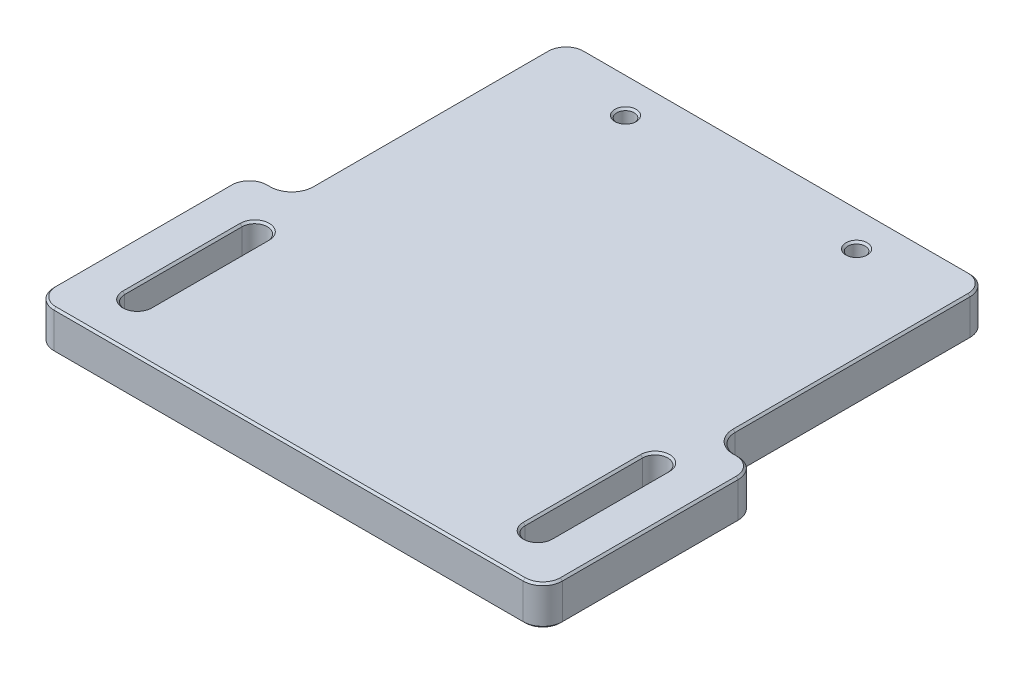
from build123d import *

# Parameters (mm, degrees)
SKETCH1_W                 = 66
SKETCH1_H                 = 63.5
BOSS_EXTRUDE1_DEPTH       = 5.08
SKETCH6_W                 = 5.5
SKETCH6_H                 = 35.589114281
CUT_EXTRUDE1_DEPTH        = 5.08
F_4_40_TAPPED_HOLE1_D     = 2.2606
F_4_40_TAPPED_HOLE1_DEPTH = 7.5946
F_4_40_TAPPED_HOLE1_TIP   = 0.679152758
FILLET1_R                 = 2.54
FILLET2_R                 = 2.54
CUT_EXTRUDE2_DEPTH        = 6.08
CHAMFER1_SIZE             = 0.254


with BuildPart() as part:
    # Sketch1 → Boss-Extrude1 (new body)
    with BuildSketch(Plane(origin=(0, 0, 0), x_dir=(1, 0, 0), z_dir=(0, 1, 0))):
        with Locations((-33, 31.75)):
            Rectangle(SKETCH1_W, SKETCH1_H)
    extrude(amount=BOSS_EXTRUDE1_DEPTH)

    # Sketch6 → Cut-Extrude1 (cut)
    with BuildSketch(Plane(origin=(0, 5.08, 0), x_dir=(1, 0, 0), z_dir=(0, 1, 0))):
        with Locations((-63.25, 45.70544286)):
            Rectangle(SKETCH6_W, SKETCH6_H)
        with Locations((-2.75, 45.70544286)):
            Rectangle(SKETCH6_W, SKETCH6_H)
    extrude(amount=-CUT_EXTRUDE1_DEPTH, mode=Mode.SUBTRACT)

    # #4-40 Tapped Hole1
    with Locations(Plane(origin=(0, 5.08, 0), x_dir=(-1, 0, 0), z_dir=(0, 1, 0))):
        with Locations((48, -58.7375), (18, -58.7375)):
            Hole(F_4_40_TAPPED_HOLE1_D / 2, depth=F_4_40_TAPPED_HOLE1_DEPTH)
            with Locations((0, 0, -(F_4_40_TAPPED_HOLE1_DEPTH + F_4_40_TAPPED_HOLE1_TIP / 2))):  # 118° drill point
                Cone(0, F_4_40_TAPPED_HOLE1_D / 2, F_4_40_TAPPED_HOLE1_TIP, mode=Mode.SUBTRACT)

    # Fillet1
    fillet1_edges = [part.edges().sort_by_distance(p)[0] for p in [
        (-60.5, 2.54, -63.5),
        (-60.5, 2.54, -27.910885719),
        (-5.5, 2.54, -27.910885719),
        (-5.5, 2.54, -63.5),
        (0, 2.54, 0),
        (-66, 2.54, 0),
    ]]
    fillet(fillet1_edges, radius=FILLET1_R)

    # Fillet2
    fillet2_edges = [part.edges().sort_by_distance(p)[0] for p in [
        (-66, 2.54, -27.910885719),
        (0, 2.54, -27.910885719),
    ]]
    fillet(fillet2_edges, radius=FILLET2_R)

    # Sketch9 → Cut-Extrude2 (cut, through all)
    with BuildSketch(Plane(origin=(0, 5.08, 0), x_dir=(1, 0, 0), z_dir=(0, 1, 0))):
        with BuildLine():
            Line((-60.6383, 6.35), (-60.6383, 21.59))
            ThreePointArc((-60.6383, 21.59), (-59, 23.2283), (-57.3617, 21.59))
            Line((-57.3617, 21.59), (-57.3617, 6.35))
            ThreePointArc((-57.3617, 6.35), (-59, 4.7117), (-60.6383, 6.35))
        make_face()
        with BuildLine():
            Line((-8.6383, 6.35), (-8.6383, 21.59))
            ThreePointArc((-8.6383, 21.59), (-7, 23.2283), (-5.3617, 21.59))
            Line((-5.3617, 21.59), (-5.3617, 6.35))
            ThreePointArc((-5.3617, 6.35), (-7, 4.7117), (-8.6383, 6.35))
        make_face()
    extrude(amount=-CUT_EXTRUDE2_DEPTH, mode=Mode.SUBTRACT)

    # Chamfer1
    chamfer1_edges = [part.edges().sort_by_distance(p)[0] for p in [
        (-59, 0, -4.7117),
        (-60.6383, 0, -13.97),
        (-59, 0, -23.2283),
        (-57.3617, 0, -13.97),
        (-59, 5.08, -4.7117),
        (-57.3617, 5.08, -13.97),
        (-59, 5.08, -23.2283),
        (-60.6383, 5.08, -13.97),
        (-7, 0, -4.7117),
        (-8.6383, 0, -13.97),
        (-7, 0, -23.2283),
        (-5.3617, 0, -13.97),
        (-7, 5.08, -4.7117),
        (-5.3617, 5.08, -13.97),
        (-7, 5.08, -23.2283),
        (-8.6383, 5.08, -13.97),
        (-19.1303, 0, -58.7375),
        (-19.1303, 5.08, -58.7375),
        (-49.1303, 0, -58.7375),
        (-49.1303, 5.08, -58.7375),
        (-33, 0, 0),
        (-33, 5.08, 0),
        (-5.5, 0, -45.705442859),
        (-2.75, 0, -27.910885719),
        (0, 0, -13.955442859),
        (-60.5, 0, -45.705442859),
        (-33, 0, -63.5),
        (-59.756051224, 0, -62.756051224),
        (-6.243948776, 0, -62.756051224),
        (-0.743948776, 0, -0.743948776),
        (-65.256051224, 0, -0.743948776),
        (-2.75, 5.08, -27.910885719),
        (-5.5, 5.08, -45.705442859),
        (-33, 5.08, -63.5),
        (-60.5, 5.08, -45.705442859),
        (0, 5.08, -13.955442859),
        (-59.756051224, 5.08, -62.756051224),
        (-6.243948776, 5.08, -62.756051224),
        (-0.743948776, 5.08, -0.743948776),
        (-65.256051224, 5.08, -0.743948776),
        (-4.756051224, 5.08, -28.654834495),
        (-4.756051224, 0, -28.654834495),
        (-61.243948776, 5.08, -28.654834495),
        (-61.243948776, 0, -28.654834495),
        (-63.25, 5.08, -27.910885719),
        (-63.25, 0, -27.910885719),
        (-66, 5.08, -13.955442859),
        (-0.743948776, 5.08, -27.166936943),
        (-65.256051224, 5.08, -27.166936943),
        (-66, 0, -13.955442859),
        (-0.743948776, 0, -27.166936943),
        (-65.256051224, 0, -27.166936943),
    ]]
    chamfer(chamfer1_edges, length=CHAMFER1_SIZE)


solid = part.part
